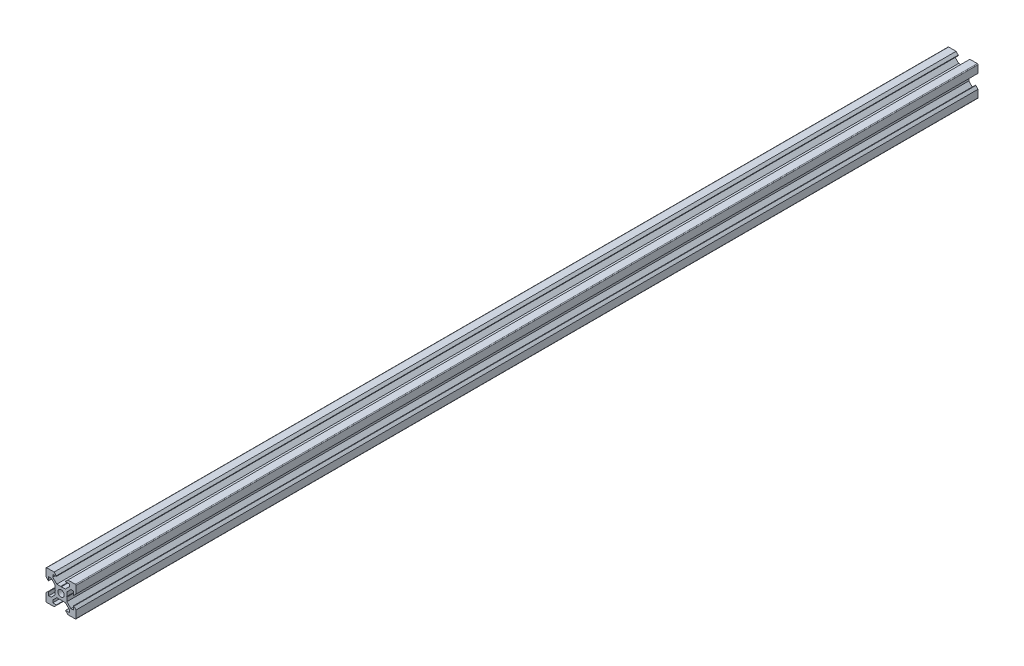
from build123d import *

# Parameters (mm, degrees)
SKETCH1_R           = 2.1
BOSS_EXTRUDE1_DEPTH = 600


with BuildPart() as part:
    # Sketch1 → Boss-Extrude1 (new body)
    with BuildSketch(Plane.XY):
        with BuildLine():
            Line((4.58, -10), (9.5, -10))
            ThreePointArc((9.5, -10), (9.853553391, -9.853553391), (10, -9.5))
            Line((10, -9.5), (10, -4.58))
            Line((10, -4.58), (8.545, -3.125))
            Line((8.545, -3.125), (8.2, -3.125))
            Line((8.2, -3.125), (8.2, -5.5))
            Line((8.2, -5.5), (6.560660172, -5.5))
            Line((6.560660172, -5.5), (3.9, -2.839339828))
            Line((3.9, -2.839339828), (3.9, -0.21))
            Line((3.9, -0.21), (3.69, 0))
            Line((3.69, 0), (3.9, 0.21))
            Line((3.9, 0.21), (3.9, 2.839339828))
            Line((3.9, 2.839339828), (6.560660172, 5.5))
            Line((6.560660172, 5.5), (8.2, 5.5))
            Line((8.2, 5.5), (8.2, 3.125))
            Line((8.2, 3.125), (8.545, 3.125))
            Line((8.545, 3.125), (10, 4.58))
            Line((10, 4.58), (10, 9.5))
            ThreePointArc((10, 9.5), (9.853553391, 9.853553391), (9.5, 10))
            Line((9.5, 10), (4.58, 10))
            Line((4.58, 10), (3.125, 8.545))
            Line((3.125, 8.545), (3.125, 8.2))
            Line((3.125, 8.2), (5.5, 8.2))
            Line((5.5, 8.2), (5.5, 6.560660172))
            Line((5.5, 6.560660172), (2.839339828, 3.9))
            Line((2.839339828, 3.9), (0.21, 3.9))
            Line((0.21, 3.9), (0, 3.69))
            Line((0, 3.69), (-0.21, 3.9))
            Line((-0.21, 3.9), (-2.839339828, 3.9))
            Line((-2.839339828, 3.9), (-5.5, 6.560660172))
            Line((-5.5, 6.560660172), (-5.5, 8.2))
            Line((-5.5, 8.2), (-3.125, 8.2))
            Line((-3.125, 8.2), (-3.125, 8.545))
            Line((-3.125, 8.545), (-4.58, 10))
            Line((-4.58, 10), (-9.5, 10))
            ThreePointArc((-9.5, 10), (-9.853553391, 9.853553391), (-10, 9.5))
            Line((-10, 9.5), (-10, 4.58))
            Line((-10, 4.58), (-8.545, 3.125))
            Line((-8.545, 3.125), (-8.2, 3.125))
            Line((-8.2, 3.125), (-8.2, 5.5))
            Line((-8.2, 5.5), (-6.560660172, 5.5))
            Line((-6.560660172, 5.5), (-3.9, 2.839339828))
            Line((-3.9, 2.839339828), (-3.9, 0.21))
            Line((-3.9, 0.21), (-3.69, 0))
            Line((-3.69, 0), (-3.9, -0.21))
            Line((-3.9, -0.21), (-3.9, -2.839339828))
            Line((-3.9, -2.839339828), (-6.560660172, -5.5))
            Line((-6.560660172, -5.5), (-8.2, -5.5))
            Line((-8.2, -5.5), (-8.2, -3.125))
            Line((-8.2, -3.125), (-8.545, -3.125))
            Line((-8.545, -3.125), (-10, -4.58))
            Line((-10, -4.58), (-10, -9.5))
            ThreePointArc((-10, -9.5), (-9.853553391, -9.853553391), (-9.5, -10))
            Line((-9.5, -10), (-4.58, -10))
            Line((-4.58, -10), (-3.125, -8.545))
            Line((-3.125, -8.545), (-3.125, -8.2))
            Line((-3.125, -8.2), (-5.5, -8.2))
            Line((-5.5, -8.2), (-5.5, -6.560660172))
            Line((-5.5, -6.560660172), (-2.839339828, -3.9))
            Line((-2.839339828, -3.9), (-0.21, -3.9))
            Line((-0.21, -3.9), (0, -3.69))
            Line((0, -3.69), (0.21, -3.9))
            Line((0.21, -3.9), (2.839339828, -3.9))
            Line((2.839339828, -3.9), (5.5, -6.560660172))
            Line((5.5, -6.560660172), (5.5, -8.2))
            Line((5.5, -8.2), (3.125, -8.2))
            Line((3.125, -8.2), (3.125, -8.545))
            Line((3.125, -8.545), (4.58, -10))
        make_face()
        Circle(SKETCH1_R, mode=Mode.SUBTRACT)
    extrude(amount=BOSS_EXTRUDE1_DEPTH)


solid = part.part
